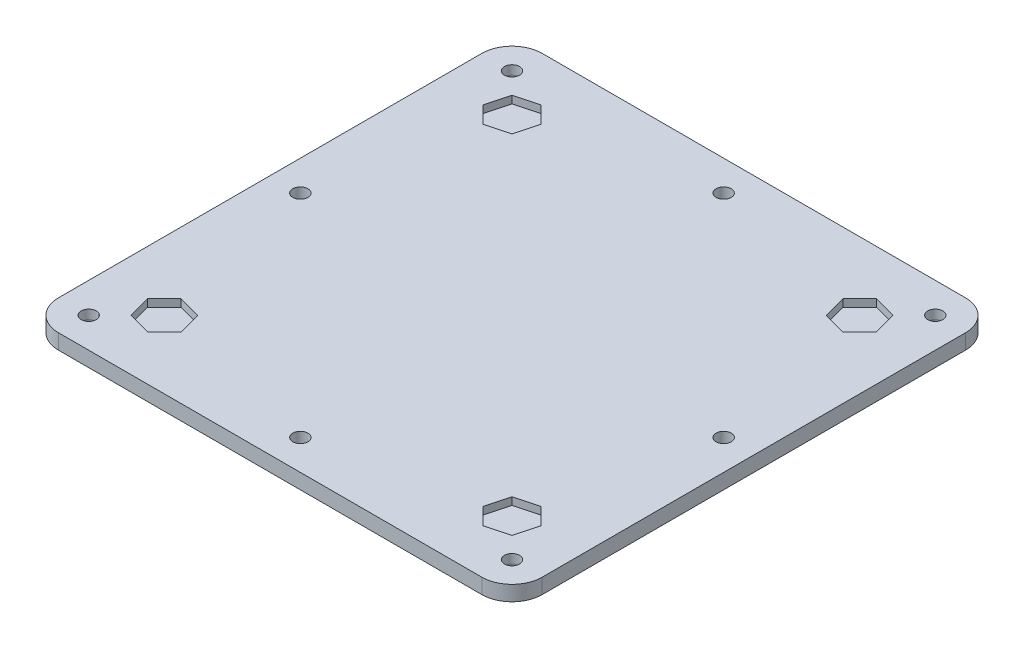
from build123d import *

# Parameters (mm, degrees)
SKETCH1_W           = 203.2
SKETCH1_H           = 203.2
BOSS_EXTRUDE1_DEPTH = 6.35
FILLET1_R           = 12.7
SKETCH2_R           = 3.175
CUT_EXTRUDE1_DEPTH  = 7.35
CUT_EXTRUDE2_DEPTH  = 3.175
FILLET2_R           = 2.54
SKETCH23_R          = 3.175
CUT_EXTRUDE3_DEPTH  = 7.35


with BuildPart() as part:
    # Sketch1 → Boss-Extrude1 (new body)
    with BuildSketch(Plane(origin=(0, 0, 0), x_dir=(1, 0, 0), z_dir=(0, 1, 0))):
        with Locations((101.6, 101.6)):
            Rectangle(SKETCH1_W, SKETCH1_H)
    extrude(amount=BOSS_EXTRUDE1_DEPTH)

    # Fillet1
    fillet1_edges = [part.edges().sort_by_distance(p)[0] for p in [
        (0, 3.175, -203.2),
        (203.2, 3.175, -203.2),
        (203.2, 3.175, 0),
        (0, 3.175, 0),
    ]]
    fillet(fillet1_edges, radius=FILLET1_R)

    # Sketch2 → Cut-Extrude1 (cut, through all)
    with BuildSketch(Plane.XZ):
        with Locations((12.7, -12.7)):
            Circle(SKETCH2_R)
        with Locations((190.5, -12.7)):
            Circle(SKETCH2_R)
        with Locations((190.5, -190.5)):
            Circle(SKETCH2_R)
        with Locations((12.7, -190.5)):
            Circle(SKETCH2_R)
    extrude(amount=-CUT_EXTRUDE1_DEPTH, mode=Mode.SUBTRACT)

    # Sketch22 → Cut-Extrude2 (cut)
    with BuildSketch(Plane(origin=(0, 6.35, 0), x_dir=(1, 0, 0), z_dir=(0, 1, 0))):
        Polygon((181.654219065, 181.654219065), (172.052127253, 184.227091812), (165.022908188, 177.197872747), (167.595780935, 167.595780935), (177.197872747, 165.022908188), (184.227091812, 172.052127253), align=None)
        Polygon((18.972908188, 172.052127253), (21.545780935, 181.654219065), (31.147872747, 184.227091812), (38.177091812, 177.197872747), (35.604219065, 167.595780935), (26.002127253, 165.022908188), align=None)
        Polygon((184.227091812, 31.147872747), (181.654219065, 21.545780935), (172.052127253, 18.972908188), (165.022908188, 26.002127253), (167.595780935, 35.604219065), (177.197872747, 38.177091812), align=None)
        Polygon((21.545780935, 21.545780935), (31.147872747, 18.972908188), (38.177091812, 26.002127253), (35.604219065, 35.604219065), (26.002127253, 38.177091812), (18.972908188, 31.147872747), align=None)
    extrude(amount=-CUT_EXTRUDE2_DEPTH, mode=Mode.SUBTRACT)

    # Fillet2
    fillet2_edges = [part.edges().sort_by_distance(p)[0] for p in [
        (9.525, 0, -190.5),
        (187.325, 0, -190.5),
        (187.325, 0, -12.7),
        (9.525, 0, -12.7),
    ]]
    fillet(fillet2_edges, radius=FILLET2_R)

    # Sketch23 → Cut-Extrude3 (cut, through all)
    with BuildSketch(Plane(origin=(0, 6.35, 0), x_dir=(1, 0, 0), z_dir=(0, 1, 0))):
        with Locations((190.5, 101.6)):
            Circle(SKETCH23_R)
        with Locations((101.6, 12.7)):
            Circle(SKETCH23_R)
        with Locations((12.7, 101.6)):
            Circle(SKETCH23_R)
        with Locations((101.6, 190.5)):
            Circle(SKETCH23_R)
    extrude(amount=-CUT_EXTRUDE3_DEPTH, mode=Mode.SUBTRACT)


solid = part.part
